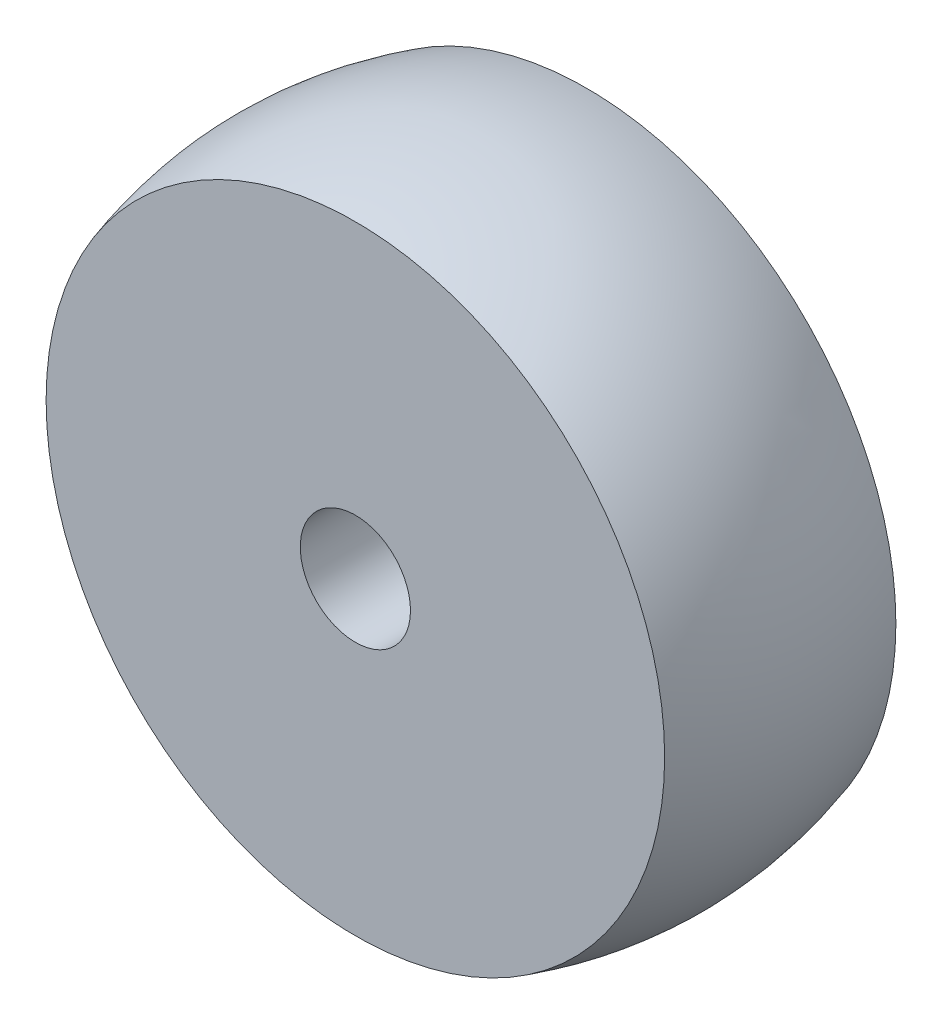
from build123d import *

# Parameters (mm, degrees)
SKETCH1_R           = 26.75
SKETCH1_R_2         = 4.765
BOSS_EXTRUDE1_DEPTH = 20


with BuildPart() as part:
    # Sketch1 → Boss-Extrude1 (new body)
    with BuildSketch(Plane.XY):
        Circle(SKETCH1_R)
        Circle(SKETCH1_R_2, mode=Mode.SUBTRACT)
    extrude(amount=BOSS_EXTRUDE1_DEPTH)

    # Sketch2 → Revolve1 (revolve)
    with BuildSketch(Plane(origin=(0, 0, 0), x_dir=(0, 0, -1), z_dir=(1, 0, 0))):
        with BuildLine():
            Line((-20, 26.75), (0, 26.75))
            add(Edge.make_bspline(
                [(-20, 26.75), (-10, 29.75), (0, 26.75)],
                knots=[0, 0, 0, 1, 1, 1], degree=2))
        make_face()
    revolve(axis=Axis((0, 0, 0), (0, 0, 1)))


solid = part.part
